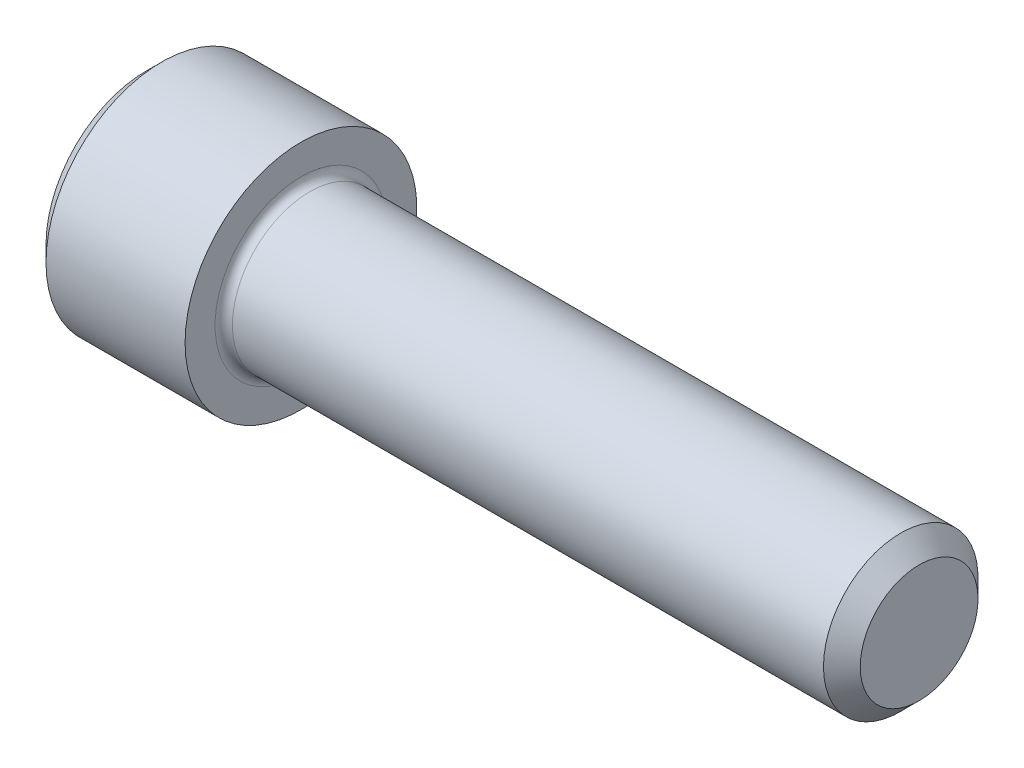
from build123d import *

# Parameters (mm, degrees)
FILLET1_R   = 0.3556
HEX_2_DEPTH = 3.048


with BuildPart() as part:
    # BodySke → Base-Revolve (revolve)
    with BuildSketch(Plane.XY):
        Polygon((0, 0), (0, 4.1275), (0.635, 4.7625), (6.35, 4.7625), (6.35, 3.175), (30.99435, 3.175), (31.75, 2.41935), (31.75, 0), align=None)
    revolve(axis=Axis((-31.75, 0, 0), (1, 0, 0)))

    # Fillet1
    fillet1_edges = [part.edges().sort_by_distance(p)[0] for p in [
        (6.35, -3.175, 0),
    ]]
    fillet(fillet1_edges, radius=FILLET1_R)

    # Sketch2 → Hex-PreBroach (revolve, cut)
    with BuildSketch(Plane.XY):
        Polygon((0, 2.38125), (3.048, 2.38125), (4.422815329, 0), (0, 0), align=None)
    revolve(axis=Axis((0, 0, 0), (1, 0, 0)), mode=Mode.SUBTRACT)

    # Sketch3 → Hex 2 (cut)
    with BuildSketch(Plane(origin=(0, 0, 0), x_dir=(0, 0.5, 0.866025404), z_dir=(-1, 0, 0))):
        Polygon((1.374815329, 2.38125), (-1.374815329, 2.38125), (-2.749630657, 0), (-1.374815329, -2.38125), (1.374815329, -2.38125), (2.749630657, 0), align=None)
    extrude(amount=-HEX_2_DEPTH, mode=Mode.SUBTRACT)


solid = part.part
